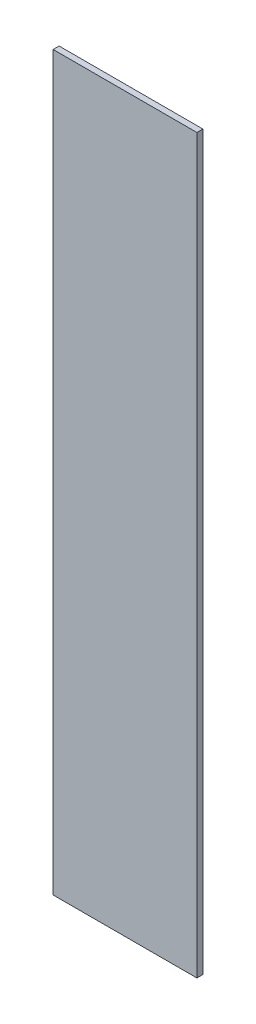
from build123d import *

# Parameters (mm, degrees)
SKETCH1_W           = 432
SKETCH1_H           = 2200
BOSS_EXTRUDE1_DEPTH = 18


with BuildPart() as part:
    # Sketch1 → Boss-Extrude1 (new body)
    with BuildSketch(Plane.XY):
        with Locations((216, 1100)):
            Rectangle(SKETCH1_W, SKETCH1_H)
    extrude(amount=BOSS_EXTRUDE1_DEPTH)


solid = part.part
